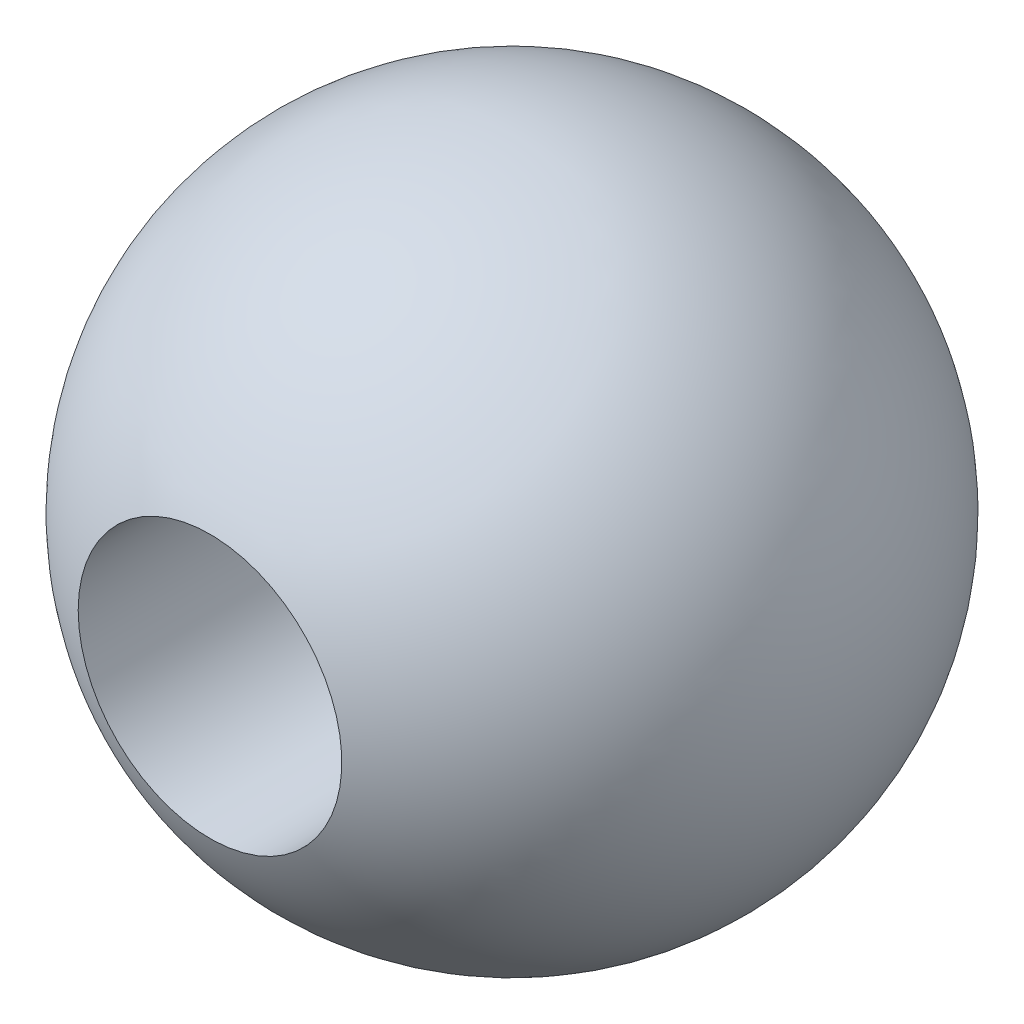
from build123d import *

# Parameters (mm, degrees)
SKETCH2_R               = 2.54
CUT_EXTRUDE1_DEPTH      = 7.35
CUT_EXTRUDE1_DEPTH_BACK = 7.35


with BuildPart() as part:
    # Sketch1 → Revolve1 (revolve)
    with BuildSketch(Plane.XY):
        with BuildLine():
            Line((0, 6.35), (0, -6.35))
            ThreePointArc((0, -6.35), (6.35, 0), (0, 6.35))
        make_face()
    revolve(axis=Axis((0, 6.35, 0), (0, -1, 0)))

    # Sketch2 → Cut-Extrude1 (cut, two sides)
    with BuildSketch(Plane.XY) as cut_extrude1_sk:
        Circle(SKETCH2_R)
    extrude(amount=CUT_EXTRUDE1_DEPTH, mode=Mode.SUBTRACT)
    extrude(cut_extrude1_sk.sketch, amount=-CUT_EXTRUDE1_DEPTH_BACK, mode=Mode.SUBTRACT)


solid = part.part
